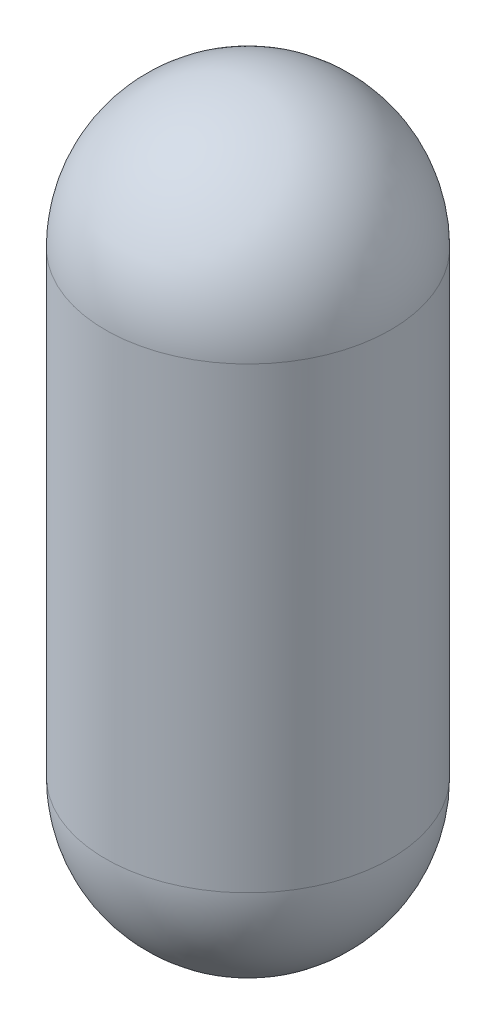
from build123d import *


with BuildPart() as part:
    # Sketch1 → Revolve1 (revolve)
    with BuildSketch(Plane.XY):
        with BuildLine():
            Line((0, 1815.66), (0, 1818.2))
            ThreePointArc((0, 1818.2), (305.328708116, 1691.728708116), (431.8, 1386.4))
            Line((431.8, 1386.4), (431.8, 0))
            ThreePointArc((431.8, 0), (305.328708116, -305.328708116), (0, -431.8))
            Line((0, -431.8), (0, -429.26))
            ThreePointArc((0, -429.26), (303.532656892, -303.532656892), (429.26, 0))
            Line((429.26, 0), (429.26, 1386.4))
            ThreePointArc((429.26, 1386.4), (303.532656892, 1689.932656892), (0, 1815.66))
        make_face()
    revolve(axis=Axis((0, 0, 0), (0, 1, 0)))


solid = part.part
